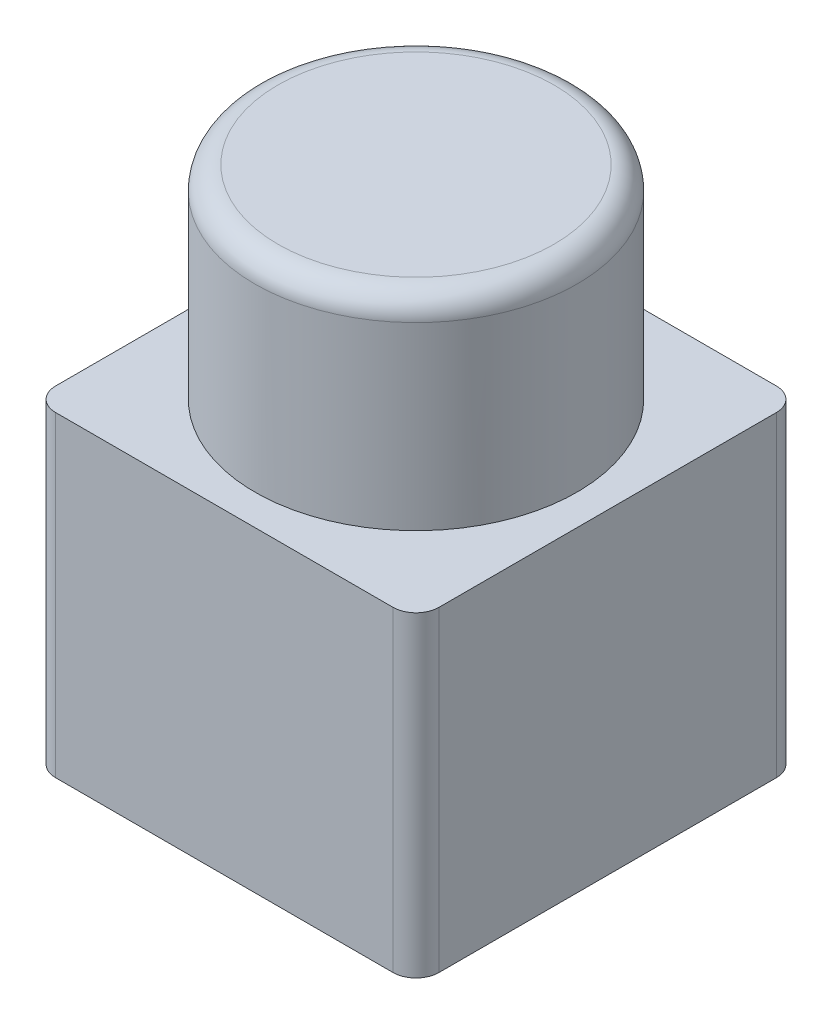
from build123d import *

# Parameters (mm, degrees)
SKETCH1_W           = 50
SKETCH1_H           = 50
BOSS_EXTRUDE1_DEPTH = 41.25
SKETCH2_R           = 1.5
CUT_EXTRUDE1_DEPTH  = 6
SKETCH3_R           = 21
BOSS_EXTRUDE2_DEPTH = 26.5
FILLET1_R           = 3


with BuildPart() as part:
    # Sketch1 → Boss-Extrude1 (new body)
    with BuildSketch(Plane(origin=(0, 0, 0), x_dir=(1, 0, 0), z_dir=(0, 1, 0))):
        with Locations((25, 25)):
            Rectangle(SKETCH1_W, SKETCH1_H)
    extrude(amount=BOSS_EXTRUDE1_DEPTH)

    # Sketch2 → Cut-Extrude1 (cut)
    with BuildSketch(Plane.XZ):
        with Locations((5, -5)):
            Circle(SKETCH2_R)
        with Locations((45, -45)):
            Circle(SKETCH2_R)
    extrude(amount=-CUT_EXTRUDE1_DEPTH, mode=Mode.SUBTRACT)

    # Sketch3 → Boss-Extrude2 (add)
    with BuildSketch(Plane(origin=(0, 41.25, 0), x_dir=(1, 0, 0), z_dir=(0, 1, 0))):
        with Locations((25, 25)):
            Circle(SKETCH3_R)
    extrude(amount=BOSS_EXTRUDE2_DEPTH)

    # Fillet1
    fillet1_edges = [part.edges().sort_by_distance(p)[0] for p in [
        (4, 67.75, -25),
        (0, 20.625, 0),
        (50, 20.625, 0),
        (50, 20.625, -50),
        (0, 20.625, -50),
    ]]
    fillet(fillet1_edges, radius=FILLET1_R)


solid = part.part
